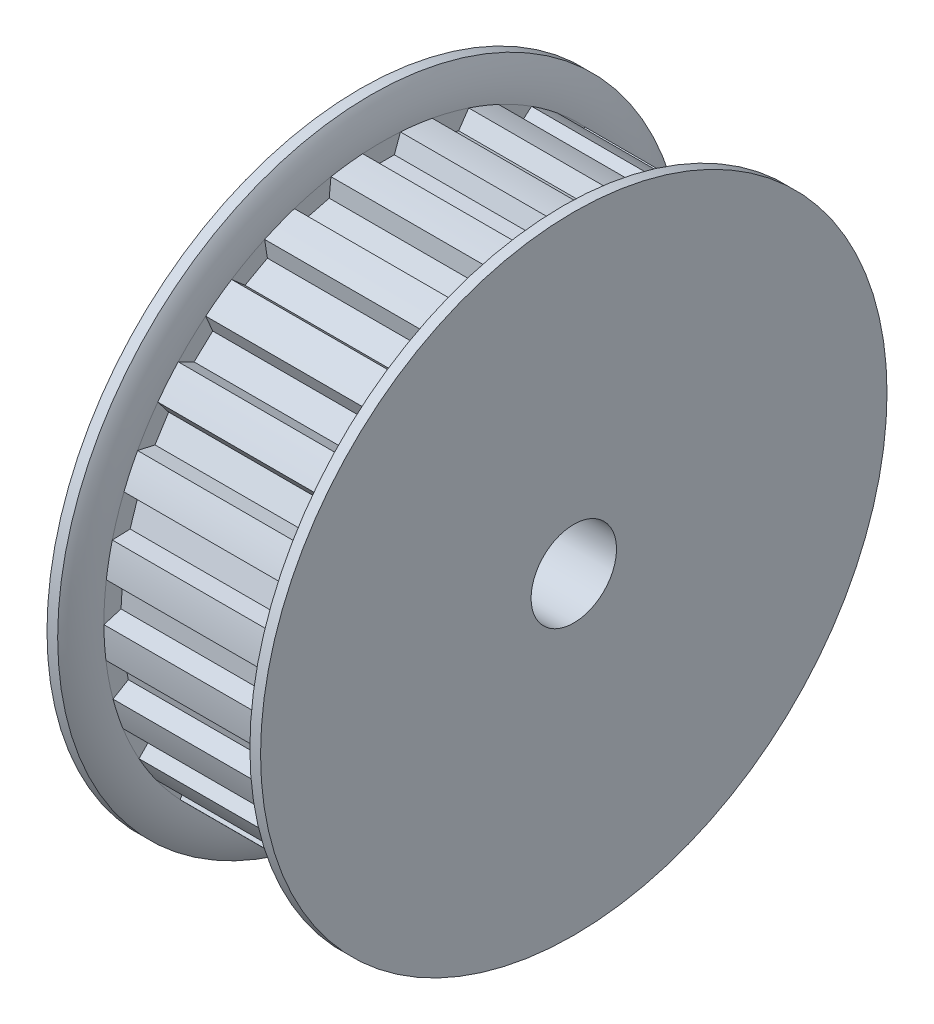
from build123d import *

# Parameters (mm, degrees)
CUT_EXTRUDE1_START = -3
CUT_EXTRUDE1_DEPTH = 12
CIRPATTERN1_COUNT  = 25


with BuildPart() as part:
    # Sketch6 → Revolve1 (revolve)
    with BuildSketch(Plane.XY):
        with BuildLine():
            Line((9.75, 22), (10.5, 22))
            Line((10.5, 22), (10.5, 3))
            Line((10.5, 3), (-10.5, 3))
            Line((-10.5, 3), (-10.5, 13))
            Line((-10.5, 13), (-4.5, 13))
            Line((-4.5, 13), (-4.5, 22))
            Line((-4.5, 22), (-3.75, 22))
            ThreePointArc((-3.75, 22), (-3.191538955, 20.805038314), (-3, 19.5))
            Line((-3, 19.5), (9, 19.5))
            ThreePointArc((9, 19.5), (9.191538955, 20.805038314), (9.75, 22))
        make_face()
    revolve(axis=Axis((-10.5, 0, 0), (1, 0, 0)))

    # Sketch3 → Cut-Extrude1 (cut)
    with BuildSketch(Plane(origin=(0, 0, 0), x_dir=(0, 0, -1), z_dir=(1, 0, 0)).offset(CUT_EXTRUDE1_START)):
        with BuildLine():
            Line((-1.325, 19.454931894), (-0.896639329, 18.278020624))
            Line((-0.896639329, 18.278020624), (0.896639329, 18.278020624))
            Line((0.896639329, 18.278020624), (1.325, 19.454931894))
            ThreePointArc((1.325, 19.454931894), (0, 19.5), (-1.325, 19.454931894))
        make_face()
    cut_extrude1 = extrude(amount=CUT_EXTRUDE1_DEPTH, mode=Mode.SUBTRACT)

    # CirPattern1: Cut-Extrude1 ×25 about axis
    cirpattern1_axis = Axis((0, 0, 0), (1, 0, 0))
    for i in range(1, CIRPATTERN1_COUNT):
        add(cut_extrude1.rotate(cirpattern1_axis, i * 360 / CIRPATTERN1_COUNT), mode=Mode.SUBTRACT)


solid = part.part
